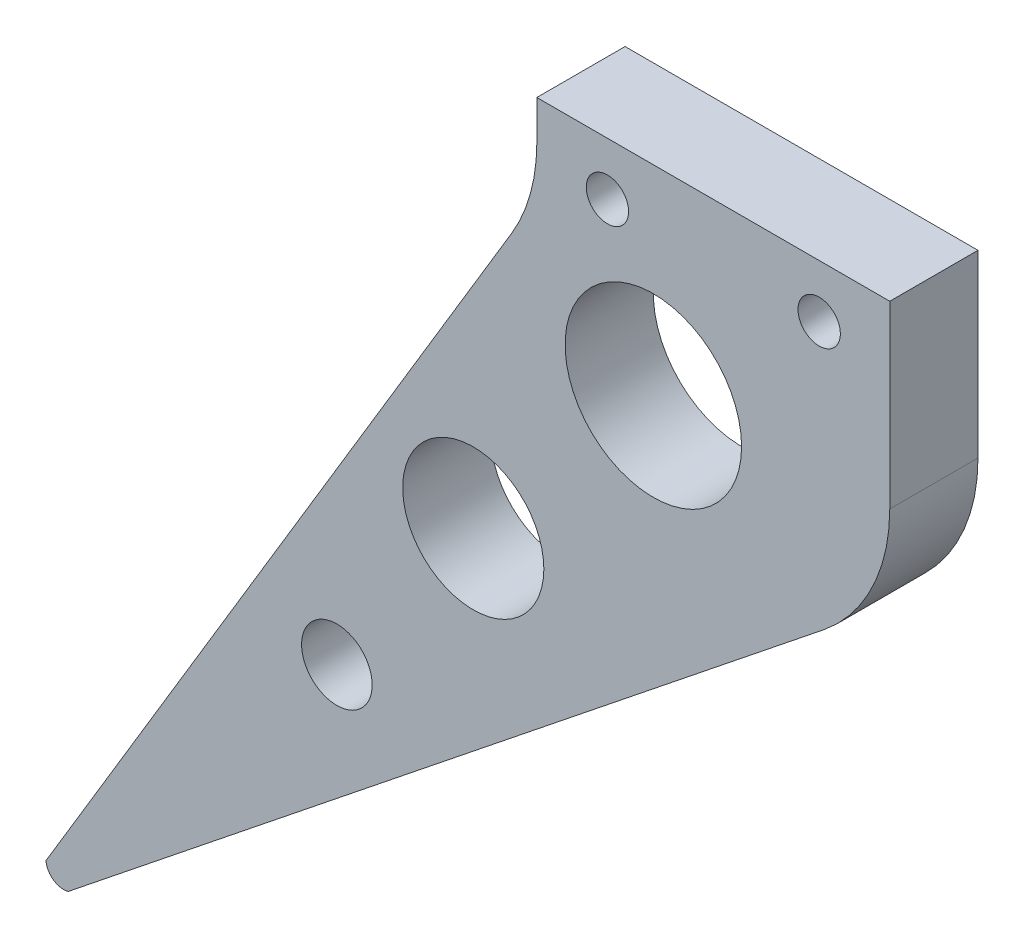
from build123d import *

# Parameters (mm, degrees)
ESQUISSE1_R                  = 5
ESQUISSE1_R_2                = 4
ESQUISSE1_R_3                = 2
BOSS_EXTRU_1_DEPTH           = 5
ENL_V_MAT_EXTRU_1_DEPTH      = 1
ENL_V_MAT_EXTRU_1_DEPTH_BACK = 5
CONG_1_R                     = 10
ESQUISSE3_W                  = 20
ESQUISSE3_H                  = 5
BOSS_EXTRU_2_DEPTH           = 5
D_GAGEMENT_M21_D             = 2.4
D_GAGEMENT_M21_DEPTH         = 5
CONG_2_R                     = 10


with BuildPart() as part:
    # Esquisse1 → Boss.-Extru.1 (new body)
    with BuildSketch(Plane.XY):
        Polygon((0, 0), (30, 50), (50, 50), (50, 40), align=None)
        with Locations((36.602361653, 43.673429465)):
            Circle(ESQUISSE1_R, mode=Mode.SUBTRACT)
        with Locations((26.397486101, 32.05434035)):
            Circle(ESQUISSE1_R_2, mode=Mode.SUBTRACT)
        with Locations((18.668376917, 21.496804042)):
            Circle(ESQUISSE1_R_3, mode=Mode.SUBTRACT)
    extrude(amount=BOSS_EXTRU_1_DEPTH)

    # Esquisse2 → Enlèv. mat.-Extru.1 (cut, two sides)
    with BuildSketch(Plane(origin=(0, 0, 0), x_dir=(-1, 0, 0), z_dir=(0, 0, -1))) as enl_v_mat_extru_1_sk:
        with BuildLine():
            Line((0, 0), (-2.185666909, 3.642778182))
            ThreePointArc((-2.185666909, 3.642778182), (-2.607581993, 2.90339912), (-3.446178626, 2.756942901))
            Line((-3.446178626, 2.756942901), (0, 0))
        make_face()
    extrude(amount=ENL_V_MAT_EXTRU_1_DEPTH, mode=Mode.SUBTRACT)
    extrude(enl_v_mat_extru_1_sk.sketch, amount=-ENL_V_MAT_EXTRU_1_DEPTH_BACK, mode=Mode.SUBTRACT)

    # Congé1
    cong_1_edges = [part.edges().sort_by_distance(p)[0] for p in [
        (50, 40, 2.5),
    ]]
    fillet(cong_1_edges, radius=CONG_1_R)

    # Esquisse3 → Boss.-Extru.2 (add)
    with BuildSketch(Plane(origin=(0, 50, 0), x_dir=(1, 0, 0), z_dir=(0, 1, 0))):
        with Locations((40, -2.5)):
            Rectangle(ESQUISSE3_W, ESQUISSE3_H)
    extrude(amount=BOSS_EXTRU_2_DEPTH)

    # Dégagement M21
    with Locations(Plane.XY.offset(5)):
        with Locations((46, 52), (34, 52)):
            Hole(D_GAGEMENT_M21_D / 2, depth=D_GAGEMENT_M21_DEPTH)

    # Congé2
    cong_2_edges = [part.edges().sort_by_distance(p)[0] for p in [
        (30, 50, 2.5),
    ]]
    fillet(cong_2_edges, radius=CONG_2_R)


solid = part.part
